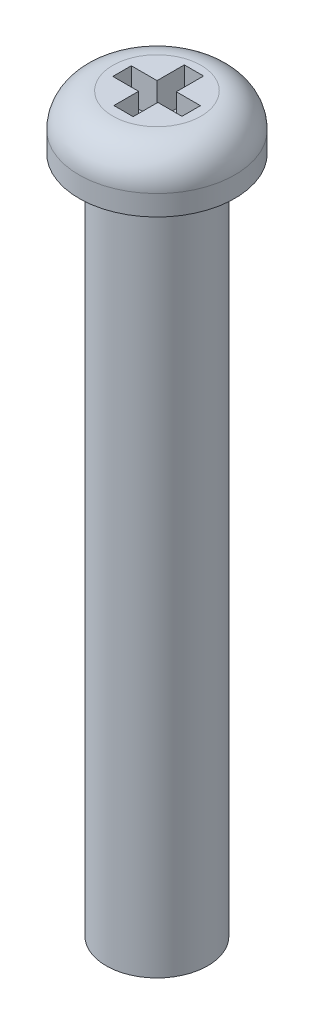
from build123d import *

# Parameters (mm, degrees)
CUT_EXTRUDE_1_DEPTH = 1


with BuildPart() as part:
    # 草圖2 → 旋轉1 (revolve)
    with BuildSketch(Plane.XY):
        with BuildLine():
            Line((0, 0), (1.5, 0))
            Line((1.5, 0), (1.5, 20))
            Line((1.5, 20), (2.3, 20))
            Line((2.3, 20), (2.3, 20.6))
            ThreePointArc((2.3, 20.6), (2.007106781, 21.307106781), (1.3, 21.6))
            Line((1.3, 21.6), (0, 21.6))
            Line((0, 21.6), (0, 0))
        make_face()
    revolve(axis=Axis((0, 21.6, 0), (0, -1, 0)))

    # 草圖3 → 除料-伸長1 (cut)
    with BuildSketch(Plane(origin=(0, 21.6, 0), x_dir=(1, 0, 0), z_dir=(0, 1, 0))):
        Polygon((-0.257139239, 0.26020042), (-0.257139239, 1.063618051), (0.311378397, 1.063618051), (0.311378397, 0.26020042), (1.022434592, 0.26020042), (1.022434592, -0.285133973), (0.311378397, -0.285133973), (0.311378397, -1.013251047), (-0.257139239, -1.013251047), (-0.257139239, -0.285133973), (-1.016312229, -0.285133973), (-1.016312229, 0.26020042), align=None)
    extrude(amount=-CUT_EXTRUDE_1_DEPTH, mode=Mode.SUBTRACT)


solid = part.part
